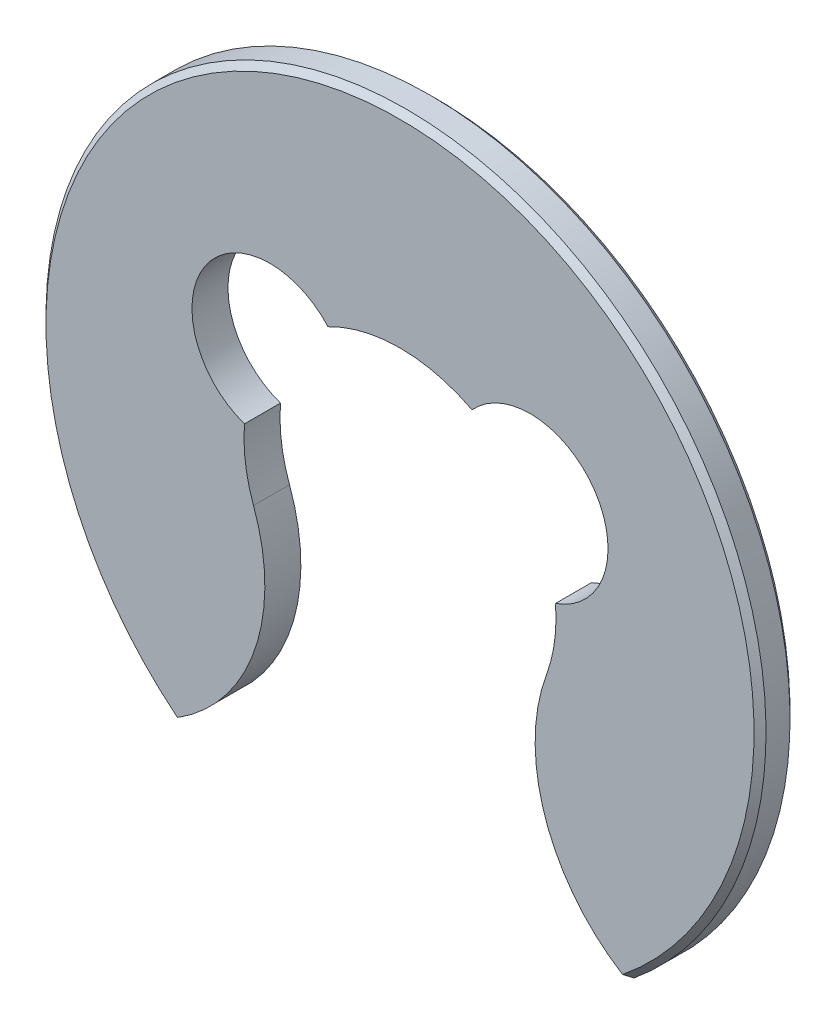
from build123d import *

# Parameters (mm, degrees)
EXTRUDE_1_DEPTH = 0.3
CHAMFER_1_SIZE  = 0.05


with BuildPart() as part:
    # 草图1 → 凸台-拉伸1 (new body)
    with BuildSketch(Plane.XY):
        with BuildLine():
            ThreePointArc((-1.295808382, 0.104310288), (-1.288091369, -0.175558041), (-1.220629908, -0.44728361))
            ThreePointArc((-1.220629908, -0.44728361), (-1.21876562, -1.508256965), (-1.9, -2.321637353))
            ThreePointArc((-1.9, -2.321637353), (0, 3), (1.9, -2.321637353))
            ThreePointArc((1.9, -2.321637353), (1.21876562, -1.508256965), (1.220629908, -0.44728361))
            ThreePointArc((1.220629908, -0.44728361), (1.288091369, -0.175558041), (1.295808382, 0.104310288))
            ThreePointArc((1.295808382, 0.104310288), (1.625, 1.077903057), (0.600024951, 1.153243278))
            ThreePointArc((0.600024951, 1.153243278), (0, 1.3), (-0.600024951, 1.153243278))
            ThreePointArc((-0.600024951, 1.153243278), (-1.625, 1.077903057), (-1.295808382, 0.104310288))
        make_face()
    extrude(amount=EXTRUDE_1_DEPTH)

    # 倒角1
    chamfer_1_edges = [part.edges().sort_by_distance(p)[0] for p in [
        (0, 3, 0.3),
        (0, 3, 0),
    ]]
    chamfer(chamfer_1_edges, length=CHAMFER_1_SIZE)


solid = part.part
